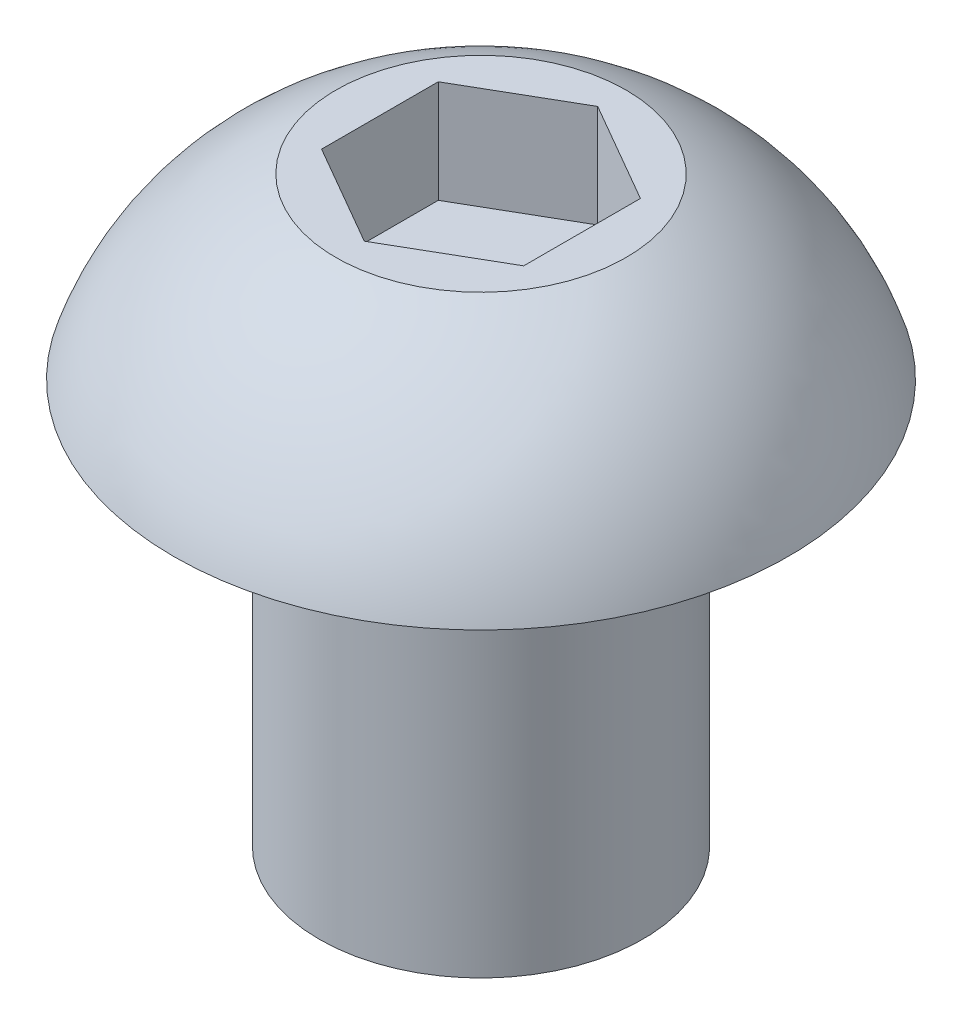
from build123d import *

# Parameters (mm, degrees)
CUT_EXTRUDE1_DEPTH = 1.27


with BuildPart() as part:
    # Sketch1 → Revolve1 (revolve)
    with BuildSketch(Plane.XY):
        with BuildLine():
            Line((-2, 0), (-3.8, 0))
            ThreePointArc((-3.8, 0), (-3.038270032, 1.319559026), (-1.79477003, 2.2))
            Line((-1.79477003, 2.2), (0, 2.2))
            Line((0, 2.2), (0, -5))
            Line((0, -5), (-2, -5))
            Line((-2, -5), (-2, 0))
        make_face()
    revolve(axis=Axis((0, -5, 0), (0, 1, 0)))

    # Sketch2 → Cut-Extrude1 (cut)
    with BuildSketch(Plane(origin=(0, 2.2, 0), x_dir=(1, 0, 0), z_dir=(0, 1, 0))):
        Polygon((-1.25, 0.721687836), (-1.25, -0.721687836), (0, -1.443375673), (1.25, -0.721687836), (1.25, 0.721687836), (0, 1.443375673), align=None)
    extrude(amount=-CUT_EXTRUDE1_DEPTH, mode=Mode.SUBTRACT)


solid = part.part
